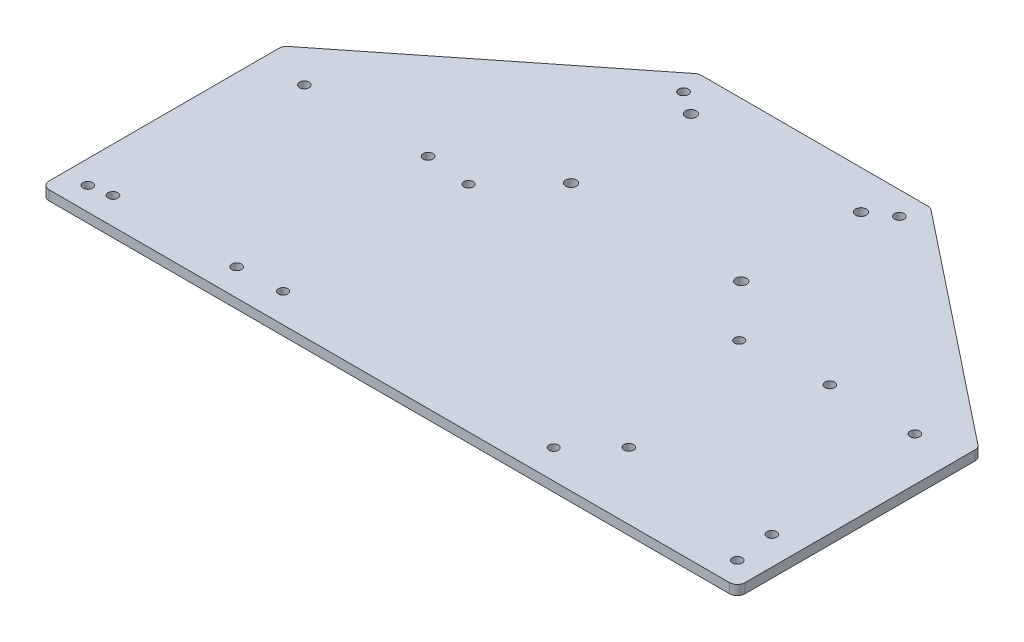
from build123d import *

# Parameters (mm, degrees)
SKETCH1_W           = 228.6
SKETCH1_H           = 139.7
SKETCH1_R           = 1.778
BOSS_EXTRUDE1_DEPTH = 3.175
SKETCH3_R           = 1.524
CUT_EXTRUDE1_DEPTH  = 4.175
SKETCH4_R           = 1.5875
CUT_EXTRUDE2_DEPTH  = 4.175
SKETCH5_R           = 1.5875
CUT_EXTRUDE3_DEPTH  = 4.175
CUT_EXTRUDE4_DEPTH  = 4.175
FILLET1_R           = 2.54
SKETCH7_R           = 1.5875
CUT_EXTRUDE5_DEPTH  = 4.175


with BuildPart() as part:
    # Sketch1 → Boss-Extrude1 (new body)
    with BuildSketch(Plane(origin=(0, 0, 0), x_dir=(1, 0, 0), z_dir=(0, 1, 0))):
        with Locations((114.3, 69.85)):
            Rectangle(SKETCH1_W, SKETCH1_H)
        with Locations((86.36, 127)):
            Circle(SKETCH1_R, mode=Mode.SUBTRACT)
        with Locations((142.24, 127)):
            Circle(SKETCH1_R, mode=Mode.SUBTRACT)
        with Locations((86.36, 87.63)):
            Circle(SKETCH1_R, mode=Mode.SUBTRACT)
        with Locations((142.24, 87.63)):
            Circle(SKETCH1_R, mode=Mode.SUBTRACT)
    extrude(amount=BOSS_EXTRUDE1_DEPTH)

    # Sketch3 → Cut-Extrude1 (cut, through all)
    with BuildSketch(Plane(origin=(0, 3.175, 0), x_dir=(1, 0, 0), z_dir=(0, 1, 0))):
        with Locations((69.85, 70.485)):
            Circle(SKETCH3_R)
        with Locations((158.75, 70.485)):
            Circle(SKETCH3_R)
        with Locations((158.75, 9.525)):
            Circle(SKETCH3_R)
        with Locations((69.85, 9.525)):
            Circle(SKETCH3_R)
    extrude(amount=-CUT_EXTRUDE1_DEPTH, mode=Mode.SUBTRACT)

    # Sketch4 → Cut-Extrude2 (cut, through all)
    with BuildSketch(Plane(origin=(0, 3.175, 0), x_dir=(1, 0, 0), z_dir=(0, 1, 0))):
        with Locations((171.0182, 21.94814)):
            Circle(SKETCH4_R)
        with Locations((186.2582, 72.74814)):
            Circle(SKETCH4_R)
        with Locations((214.1982, 72.74814)):
            Circle(SKETCH4_R)
        with Locations((219.2782, 20.67814)):
            Circle(SKETCH4_R)
    extrude(amount=-CUT_EXTRUDE2_DEPTH, mode=Mode.SUBTRACT)

    # Sketch5 → Cut-Extrude3 (cut, through all)
    with BuildSketch(Plane(origin=(0, 3.175, 0), x_dir=(1, 0, 0), z_dir=(0, 1, 0))):
        with Locations((14.605, 71.755)):
            Circle(SKETCH5_R)
        with Locations((55.245, 71.755)):
            Circle(SKETCH5_R)
        with Locations((55.245, 8.89)):
            Circle(SKETCH5_R)
        with Locations((14.605, 8.89)):
            Circle(SKETCH5_R)
    extrude(amount=-CUT_EXTRUDE3_DEPTH, mode=Mode.SUBTRACT)

    # Sketch6 → Cut-Extrude4 (cut, through all)
    with BuildSketch(Plane(origin=(0, 3.175, 0), x_dir=(1, 0, 0), z_dir=(0, 1, 0))):
        Polygon((228.6, 79.248), (152.4, 139.7), (228.6, 139.7), align=None)
        Polygon((76.2, 139.7), (0, 139.7), (0, 79.248), align=None)
    extrude(amount=-CUT_EXTRUDE4_DEPTH, mode=Mode.SUBTRACT)

    # Fillet1
    fillet1_edges = [part.edges().sort_by_distance(p)[0] for p in [
        (228.6, 1.5875, 0),
        (0, 1.5875, 0),
        (228.6, 1.5875, -79.248),
        (152.4, 1.5875, -139.7),
        (76.2, 1.5875, -139.7),
        (0, 1.5875, -79.248),
    ]]
    fillet(fillet1_edges, radius=FILLET1_R)

    # Sketch7 → Cut-Extrude5 (cut, through all)
    with BuildSketch(Plane(origin=(0, 3.175, 0), x_dir=(1, 0, 0), z_dir=(0, 1, 0))):
        with Locations((220.98, 7.62)):
            Circle(SKETCH7_R)
        with Locations((149.744486069, 132.08)):
            Circle(SKETCH7_R)
        with Locations((7.62, 7.62)):
            Circle(SKETCH7_R)
        with Locations((78.855513931, 132.08)):
            Circle(SKETCH7_R)
    extrude(amount=-CUT_EXTRUDE5_DEPTH, mode=Mode.SUBTRACT)


solid = part.part
